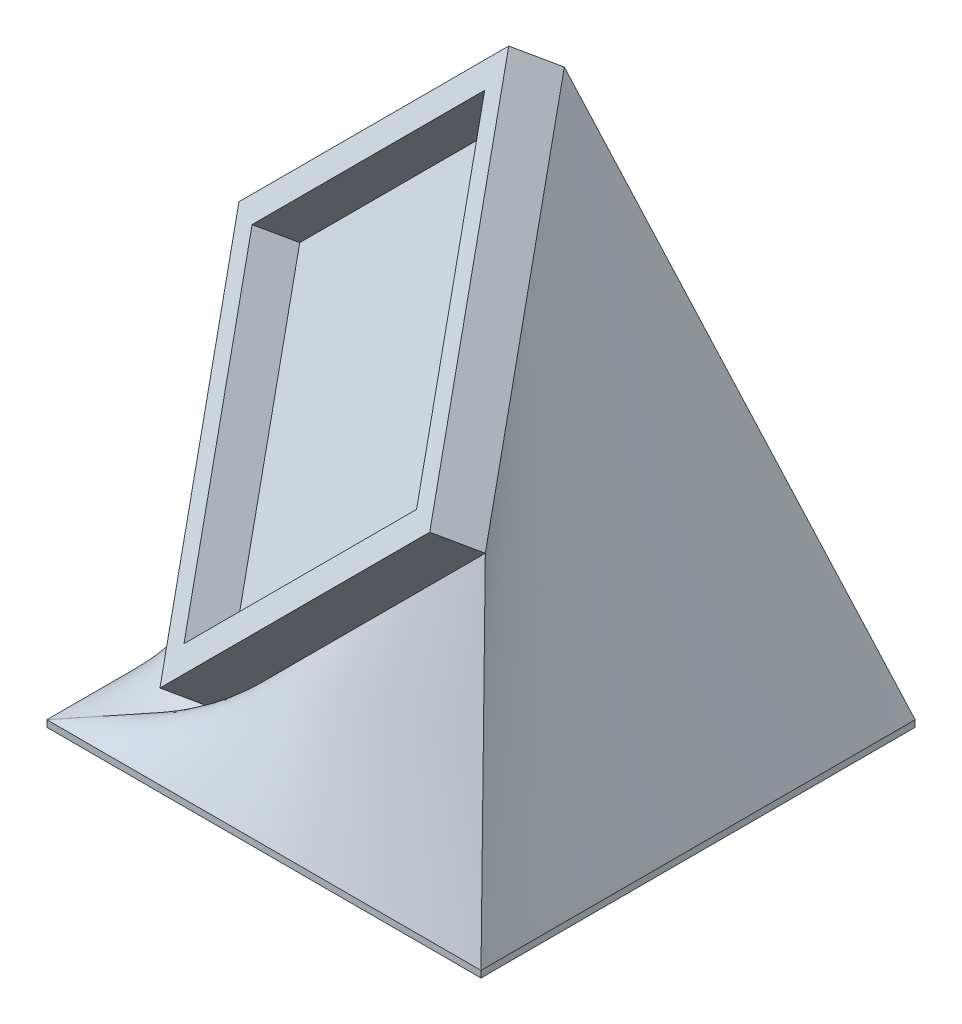
from build123d import *

# Parameters (mm, degrees)
SKETCH1_W             = 36.83
SKETCH1_H             = 36.83
BOSS_EXTRUDE1_DEPTH   = 0.635
SKETCH2_W             = 36.83
SKETCH2_H             = 36.83
SKETCH2_W_2           = 31.75
SKETCH2_H_2           = 31.75
BOSS_EXTRUDE2_DEPTH   = 3.81
SKETCH3_W             = 41.91
SKETCH3_H             = 41.91
BOSS_EXTRUDE3_DEPTH   = 0.635
BODY_MOVE_COPY2_ANGLE = 62.79942962
CUT_EXTRUDE1_DEPTH    = 0.635


with BuildPart() as part:
    # Sketch1 → Boss-Extrude1 (new body)
    with BuildSketch(Plane(origin=(0, 0, 0), x_dir=(1, 0, 0), z_dir=(0, 1, 0))):
        with Locations((-3.873751075, -5.413720286)):
            Rectangle(SKETCH1_W, SKETCH1_H)
    extrude(amount=BOSS_EXTRUDE1_DEPTH)

    # Sketch2 → Boss-Extrude2 (add)
    with BuildSketch(Plane(origin=(0, 0.635, 0), x_dir=(1, 0, 0), z_dir=(0, 1, 0))):
        with Locations((-3.873751075, -5.413720286)):
            Rectangle(SKETCH2_W, SKETCH2_H)
        with Locations((-3.873751075, -5.413720286)):
            Rectangle(SKETCH2_W_2, SKETCH2_H_2, mode=Mode.SUBTRACT)
    extrude(amount=BOSS_EXTRUDE2_DEPTH)


with BuildPart() as part_1:
    # Body-Move/Copy1: moved
    add(part.part.moved(Location((0, 20.32, 0))))


with BuildPart() as body_2:
    # Sketch3 → Boss-Extrude3 (new body)
    with BuildSketch(Plane(origin=(0, 0, 0), x_dir=(1, 0, 0), z_dir=(0, 1, 0))):
        with Locations((-3.873751075, -5.413720286)):
            Rectangle(SKETCH3_W, SKETCH3_H)
    extrude(amount=BOSS_EXTRUDE3_DEPTH)


with BuildPart() as part_2:
    # Body-Move/Copy2: moved
    add(part_1.part.moved(Location((0, 0, 0))).rotate(Axis((-5.491316546, 4.092482444, 3.796154814), (0.6785983445458468, 0.2810846377148209, 0.678598344545847)), BODY_MOVE_COPY2_ANGLE))


with BuildPart() as part_3:
    # Body-Move/Copy3: moved
    add(part_2.part.moved(Location((0, 12.437292866, -9.987032066))))


    add(body_2.part)  # loft1 joins it to this body
    # loft from a face of the part (loft1)
    loft([part_3.faces().sort_by_distance((-11.652501075, 24.978542866, 6.427501968))[0], part_3.faces().sort_by_distance((-3.873751075, 0.635, 5.413720286))[0]])

    # Sketch4 → Cut-Extrude1 (cut)
    with BuildSketch(Plane(origin=(-16.092795871, 16.092795871, -22.758650178), x_dir=(0.86512392830509, 0.32561964152545686, -0.3814871396610934), z_dir=(-0.5000000000000019, 0.5, -0.7071067811865464))):
        Polygon((7.445194673, -36.161925979), (7.385599321, -36.12336428), (8.691789224, -34.08029537), (8.337021596, -33.85383303), (8.516508776, -33.57268319), (8.871276404, -33.79914553), (9.30737416, -33.116954024), (9.600443071, -33.304153543), (9.164345314, -33.986345049), (10.565887782, -34.882378703), align=None)
        Polygon((8.984858135, -34.267494889), (8.203107333, -35.489550178), (9.847939064, -34.819277742), align=None, mode=Mode.SUBTRACT)
        with BuildLine():
            Line((4.956062153, -34.463320688), (5.134147088, -34.184274213))
            Line((5.134147088, -34.184274213), (6.178818563, -34.852443284))
            Line((6.178818563, -34.852443284), (6.835769685, -34.146413636))
            add(Edge.make_bspline(
                [(6.835769685, -34.146413636), (6.799395514, -34.134925442), (6.72899478, -34.112690506), (6.629131295, -34.073342286), (6.538222536, -34.030320212), (6.482635628, -33.997038982), (6.455761672, -33.980948893)],
                knots=[0, 0, 0, 0, 1.100853135, 2.130656675, 3.096250331, 4, 4, 4, 4], degree=3))
            add(Edge.make_bspline(
                [(6.455761672, -33.980948893), (6.423497851, -33.959393917), (6.360055887, -33.91700929), (6.27469893, -33.843430332), (6.198287725, -33.76521382), (6.131091372, -33.681812754), (6.074979038, -33.591791904), (6.027344858, -33.497021125), (5.991222737, -33.395820273), (5.963898196, -33.290520204), (5.94682734, -33.182495923), (5.942307381, -33.073909498), (5.947627582, -32.966076112), (5.964716922, -32.858703553), (5.993130935, -32.752015777), (6.031677186, -32.645433378), (6.082672755, -32.539916936), (6.123584939, -32.471826959), (6.144463595, -32.4370787)],
                knots=[0, 0, 0, 0, 1.054119066, 2.072767038, 3.056840284, 4.024383738, 4.978120495, 5.935765117, 6.902619787, 7.893582253, 8.890212225, 9.869761918, 10.843275158, 11.82107151, 12.819785659, 13.840927652, 14.898163751, 16, 16, 16, 16], degree=3))
            add(Edge.make_bspline(
                [(6.144463595, -32.4370787), (6.160052474, -32.413495108), (6.19098364, -32.366700979), (6.242409829, -32.300720354), (6.297396609, -32.239086652), (6.354500409, -32.180771017), (6.41520545, -32.127138938), (6.479388969, -32.078071543), (6.546274768, -32.032365392), (6.616668823, -31.992028069), (6.688463154, -31.955301598), (6.761949212, -31.924754229), (6.835871162, -31.899139257), (6.910491277, -31.879705112), (6.985812817, -31.864633235), (7.062008301, -31.855606006), (7.138854152, -31.852299135), (7.241959684, -31.85383903), (7.371794149, -31.871060231), (7.526359001, -31.911790153), (7.679394727, -31.975491966), (7.775707803, -32.033142944), (7.825052537, -32.062679662)],
                knots=[0, 0, 0, 0, 0.879071886, 1.744238179, 2.599050921, 3.447192245, 4.281482485, 5.116057697, 5.958823864, 6.799172569, 7.637916262, 8.465497349, 9.272387251, 10.069360117, 10.862011513, 11.659978318, 12.453162858, 13.252915639, 14.865057387, 16.511913972, 18.212925117, 20, 20, 20, 20], degree=3))
            add(Edge.make_bspline(
                [(7.825052537, -32.062679662), (7.853928846, -32.082047458), (7.910530048, -32.120010777), (7.98785674, -32.18448575), (8.058035825, -32.252900365), (8.120502809, -32.326051332), (8.173832852, -32.404847401), (8.220595601, -32.487123016), (8.259445713, -32.574380305), (8.288908606, -32.666008006), (8.311654163, -32.759433542), (8.325052892, -32.853827595), (8.329163206, -32.947971308), (8.324792312, -33.042264364), (8.312500049, -33.136712308), (8.290126521, -33.231069395), (8.26038999, -33.325643121), (8.233460678, -33.38685862), (8.219784108, -33.417948091)],
                knots=[0, 0, 0, 0, 1.076420556, 2.109919834, 3.113289842, 4.10974142, 5.083610834, 6.056080081, 7.038095135, 8.036228312, 9.033573593, 10.013344649, 10.984384725, 11.948192787, 12.934149126, 13.929837795, 14.948628224, 16, 16, 16, 16], degree=3))
            Line((8.219784108, -33.417948091), (7.919002858, -33.22584072))
            add(Edge.make_bspline(
                [(7.919002858, -33.22584072), (7.930211986, -33.194968397), (7.951820924, -33.135452788), (7.972013033, -33.045520398), (7.982611279, -32.95993958), (7.980906256, -32.877690153), (7.969775029, -32.798002702), (7.947661809, -32.719896811), (7.915620852, -32.642882869), (7.874619996, -32.567818442), (7.824984016, -32.496618751), (7.768265083, -32.431098312), (7.704085968, -32.373042305), (7.656705589, -32.340511644), (7.632945165, -32.324198091)],
                knots=[0, 0, 0, 0, 1.145247327, 2.207805784, 3.20944791, 4.147604685, 5.070424467, 6.010458655, 6.972321222, 7.976119739, 8.989811384, 9.995761669, 10.99490987, 12, 12, 12, 12], degree=3))
            add(Edge.make_bspline(
                [(7.632945165, -32.324198091), (7.608674747, -32.309683257), (7.560868578, -32.281092954), (7.485453832, -32.24724796), (7.407980731, -32.222682201), (7.328911903, -32.205407305), (7.247732648, -32.19826982), (7.165053076, -32.197785498), (7.080529763, -32.207428224), (6.995200901, -32.224948752), (6.910734915, -32.24936873), (6.83040747, -32.283885743), (6.753865796, -32.324211208), (6.681440266, -32.37251803), (6.61368608, -32.428564033), (6.550201805, -32.492274013), (6.490863113, -32.56325852), (6.45599887, -32.615292234), (6.438233627, -32.641806265)],
                knots=[0, 0, 0, 0, 0.985300544, 1.940775937, 2.873505769, 3.814701772, 4.755933039, 5.709182672, 6.69259502, 7.715219549, 8.743766383, 9.751548159, 10.757516932, 11.756300476, 12.780708532, 13.817707424, 14.888002272, 16, 16, 16, 16], degree=3))
            add(Edge.make_bspline(
                [(6.438233627, -32.641806265), (6.423238503, -32.666302435), (6.393821531, -32.714358269), (6.359089514, -32.789838573), (6.331429372, -32.865053457), (6.311479134, -32.940342777), (6.300052745, -33.016049284), (6.297499634, -33.091980278), (6.302250646, -33.168375776), (6.315656433, -33.244254829), (6.336669473, -33.318763422), (6.365363477, -33.390584674), (6.402451717, -33.458807566), (6.445762281, -33.524717215), (6.498223773, -33.586105526), (6.55740206, -33.644982557), (6.625075749, -33.699467107), (6.674032463, -33.732630917), (6.699050935, -33.7495787)],
                knots=[0, 0, 0, 0, 1.074552979, 2.108024941, 3.10457048, 4.072388379, 5.019089455, 5.964778989, 6.91180353, 7.879977382, 8.84395055, 9.805896098, 10.768955377, 11.747004193, 12.753108225, 13.786431997, 14.868794846, 16, 16, 16, 16], degree=3))
            add(Edge.make_bspline(
                [(6.699050935, -33.7495787), (6.721532024, -33.763240555), (6.767693875, -33.791293309), (6.842784485, -33.828022085), (6.923895437, -33.863521946), (7.012412733, -33.894138031), (7.106540964, -33.924375106), (7.207928684, -33.949578367), (7.315599889, -33.973777152), (7.390062219, -33.98686349), (7.428217601, -33.993569085)],
                knots=[0, 0, 0, 0, 0.815508048, 1.674534579, 2.590138659, 3.559943509, 4.577829555, 5.655512389, 6.798656701, 8, 8, 8, 8], degree=3))
            Line((7.428217601, -33.993569085), (6.226494845, -35.275219726))
            Line((6.226494845, -35.275219726), (4.956062153, -34.463320688))
        make_face()
        Polygon((3.987938292, -32.764120683), (3.652802074, -32.549577414), (3.592505599, -31.379405138), (2.504364574, -31.815502895), (2.169228356, -31.600959626), (3.570069702, -31.044970042), (3.462798067, -29.37209344), (3.801439894, -29.588740074), (3.882770022, -30.925078215), (5.119548868, -30.431488472), (5.452581721, -30.644629497), (3.903102554, -31.258111068), align=None)
        Polygon((-1.320062718, -30.545548019), (-1.379658071, -30.50698632), (-0.073468167, -28.46391741), (-0.428235795, -28.23745507), (-0.248748616, -27.956305231), (0.106019012, -28.18276757), (0.542116769, -27.500576064), (0.835185679, -27.687775583), (0.399087923, -28.36996709), (1.800630391, -29.266000743), align=None)
        Polygon((0.219600743, -28.651116929), (-0.562150058, -29.873172218), (1.082681673, -29.202899782), align=None, mode=Mode.SUBTRACT)
        with BuildLine():
            Line((-3.809195239, -28.846942728), (-3.631110303, -28.567896253))
            Line((-3.631110303, -28.567896253), (-2.586438829, -29.236065324))
            Line((-2.586438829, -29.236065324), (-1.929487707, -28.530035677))
            add(Edge.make_bspline(
                [(-1.929487707, -28.530035677), (-1.965861877, -28.518547482), (-2.036262611, -28.496312546), (-2.136126096, -28.456964326), (-2.227034856, -28.413942252), (-2.282621764, -28.380661022), (-2.30949572, -28.364570933)],
                knots=[0, 0, 0, 0, 1.100853135, 2.130656675, 3.096250331, 4, 4, 4, 4], degree=3))
            add(Edge.make_bspline(
                [(-2.30949572, -28.364570933), (-2.34175954, -28.343015957), (-2.405201504, -28.30063133), (-2.490558461, -28.227052372), (-2.566969666, -28.14883586), (-2.634166019, -28.065434795), (-2.690278354, -27.975413944), (-2.737912533, -27.880643166), (-2.774034655, -27.779442313), (-2.801359196, -27.674142244), (-2.818430052, -27.566117963), (-2.82295001, -27.457531538), (-2.81762981, -27.349698152), (-2.800540469, -27.242325593), (-2.772126456, -27.135637817), (-2.733580205, -27.029055418), (-2.682584637, -26.923538976), (-2.641672452, -26.855448999), (-2.620793797, -26.820700741)],
                knots=[0, 0, 0, 0, 1.054119066, 2.072767038, 3.056840284, 4.024383738, 4.978120495, 5.935765117, 6.902619787, 7.893582253, 8.890212225, 9.869761918, 10.843275158, 11.82107151, 12.819785659, 13.840927652, 14.898163751, 16, 16, 16, 16], degree=3))
            add(Edge.make_bspline(
                [(-2.620793797, -26.820700741), (-2.605204918, -26.797117148), (-2.574273752, -26.750323019), (-2.522847562, -26.684342395), (-2.467860783, -26.622708692), (-2.410756982, -26.564393057), (-2.350051942, -26.510760978), (-2.285868423, -26.461693584), (-2.218982623, -26.415987432), (-2.148588568, -26.375650109), (-2.076794237, -26.338923638), (-2.003308179, -26.308376269), (-1.929386229, -26.282761297), (-1.854766115, -26.263327152), (-1.779444575, -26.248255275), (-1.703249091, -26.239228047), (-1.626403239, -26.235921175), (-1.523297708, -26.23746107), (-1.393463243, -26.254682271), (-1.238898391, -26.295412194), (-1.085862665, -26.359114006), (-0.989549589, -26.416764984), (-0.940204854, -26.446301702)],
                knots=[0, 0, 0, 0, 0.879071886, 1.744238179, 2.599050921, 3.447192245, 4.281482485, 5.116057697, 5.958823864, 6.799172569, 7.637916262, 8.465497349, 9.272387251, 10.069360117, 10.862011513, 11.659978318, 12.453162858, 13.252915639, 14.865057387, 16.511913972, 18.212925117, 20, 20, 20, 20], degree=3))
            add(Edge.make_bspline(
                [(-0.940204854, -26.446301702), (-0.911328545, -26.465669498), (-0.854727344, -26.503632817), (-0.777400652, -26.56810779), (-0.707221567, -26.636522405), (-0.644754583, -26.709673372), (-0.59142454, -26.788469441), (-0.54466179, -26.870745056), (-0.505811679, -26.958002345), (-0.476348785, -27.049630047), (-0.453603228, -27.143055582), (-0.4402045, -27.237449636), (-0.436094185, -27.331593348), (-0.44046508, -27.425886404), (-0.452757343, -27.520334349), (-0.47513087, -27.614691435), (-0.504867401, -27.709265161), (-0.531796714, -27.770480661), (-0.545473284, -27.801570132)],
                knots=[0, 0, 0, 0, 1.076420556, 2.109919834, 3.113289842, 4.10974142, 5.083610834, 6.056080081, 7.038095135, 8.036228312, 9.033573593, 10.013344649, 10.984384725, 11.948192787, 12.934149126, 13.929837795, 14.948628224, 16, 16, 16, 16], degree=3))
            Line((-0.545473284, -27.801570132), (-0.846254534, -27.60946276))
            add(Edge.make_bspline(
                [(-0.846254534, -27.60946276), (-0.835045406, -27.578590437), (-0.813436468, -27.519074828), (-0.793244359, -27.429142438), (-0.782646113, -27.34356162), (-0.784351136, -27.261312193), (-0.795482362, -27.181624742), (-0.817595582, -27.103518852), (-0.849636539, -27.02650491), (-0.890637395, -26.951440482), (-0.940273376, -26.880240791), (-0.996992309, -26.814720352), (-1.061171424, -26.756664346), (-1.108551803, -26.724133684), (-1.132312226, -26.707820132)],
                knots=[0, 0, 0, 0, 1.145247327, 2.207805784, 3.20944791, 4.147604685, 5.070424467, 6.010458655, 6.972321222, 7.976119739, 8.989811384, 9.995761669, 10.99490987, 12, 12, 12, 12], degree=3))
            add(Edge.make_bspline(
                [(-1.132312226, -26.707820132), (-1.156582645, -26.693305297), (-1.204388813, -26.664714994), (-1.279803559, -26.63087), (-1.357276661, -26.606304241), (-1.436345488, -26.589029345), (-1.517524744, -26.58189186), (-1.600204316, -26.581407538), (-1.684727628, -26.591050264), (-1.77005649, -26.608570792), (-1.854522476, -26.63299077), (-1.934849922, -26.667507783), (-2.011391595, -26.707833248), (-2.083817126, -26.75614007), (-2.151571311, -26.812186073), (-2.215055587, -26.875896053), (-2.274394278, -26.94688056), (-2.309258521, -26.998914274), (-2.327023765, -27.025428305)],
                knots=[0, 0, 0, 0, 0.985300544, 1.940775937, 2.873505769, 3.814701772, 4.755933039, 5.709182672, 6.69259502, 7.715219549, 8.743766383, 9.751548159, 10.757516932, 11.756300476, 12.780708532, 13.817707424, 14.888002272, 16, 16, 16, 16], degree=3))
            add(Edge.make_bspline(
                [(-2.327023765, -27.025428305), (-2.342018888, -27.049924476), (-2.37143586, -27.097980309), (-2.406167878, -27.173460613), (-2.43382802, -27.248675497), (-2.453778258, -27.323964817), (-2.465204647, -27.399671325), (-2.467757758, -27.475602318), (-2.463006746, -27.551997816), (-2.449600959, -27.62787687), (-2.428587918, -27.702385462), (-2.399893914, -27.774206714), (-2.362805675, -27.842429606), (-2.31949511, -27.908339255), (-2.267033618, -27.969727566), (-2.207855332, -28.028604598), (-2.140181642, -28.083089147), (-2.091224928, -28.116252957), (-2.066206457, -28.133200741)],
                knots=[0, 0, 0, 0, 1.074552979, 2.108024941, 3.10457048, 4.072388379, 5.019089455, 5.964778989, 6.91180353, 7.879977382, 8.84395055, 9.805896098, 10.768955377, 11.747004193, 12.753108225, 13.786431997, 14.868794846, 16, 16, 16, 16], degree=3))
            add(Edge.make_bspline(
                [(-2.066206457, -28.133200741), (-2.043725368, -28.146862595), (-1.997563517, -28.17491535), (-1.922472906, -28.211644126), (-1.841361954, -28.247143986), (-1.752844659, -28.277760071), (-1.658716427, -28.307997146), (-1.557328708, -28.333200407), (-1.449657502, -28.357399193), (-1.375195173, -28.37048553), (-1.33703979, -28.377191125)],
                knots=[0, 0, 0, 0, 0.815508048, 1.674534579, 2.590138659, 3.559943509, 4.577829555, 5.655512389, 6.798656701, 8, 8, 8, 8], degree=3))
            Line((-1.33703979, -28.377191125), (-2.538762547, -29.658841766))
            Line((-2.538762547, -29.658841766), (-3.809195239, -28.846942728))
        make_face()
    extrude(amount=-CUT_EXTRUDE1_DEPTH, mode=Mode.SUBTRACT)


solid = part_3.part
